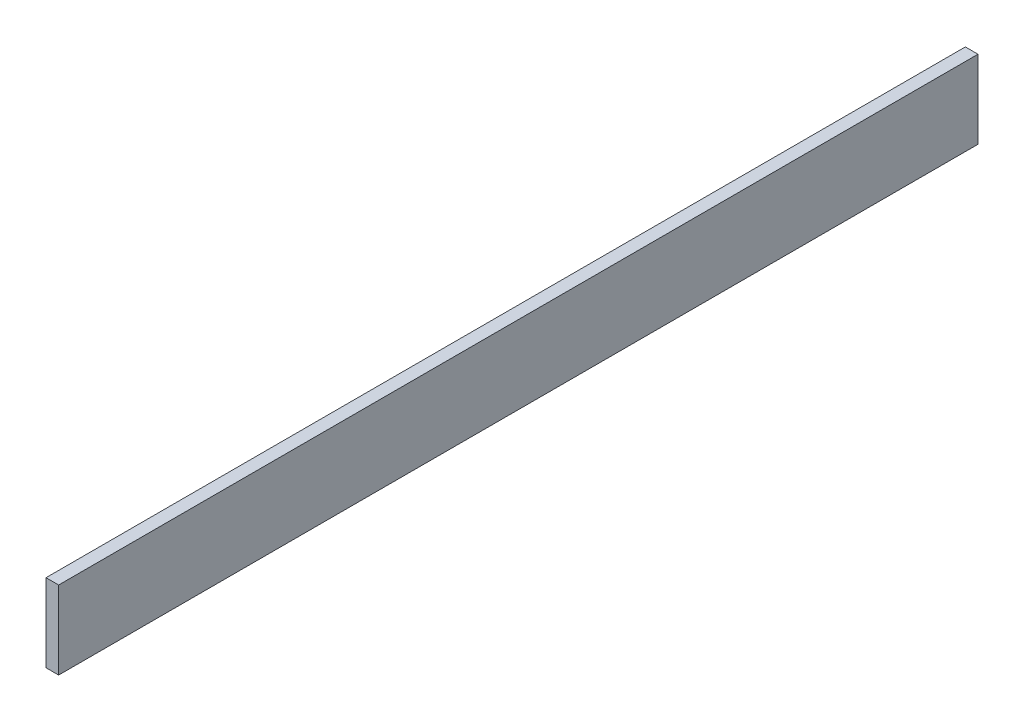
from build123d import *

# Parameters (mm, degrees)
SKETCH1_W           = 2768.6
SKETCH1_H           = 234.95
BOSS_EXTRUDE1_DEPTH = 38.1


with BuildPart() as part:
    # Sketch1 → Boss-Extrude1 (new body)
    with BuildSketch(Plane(origin=(0, 0, 0), x_dir=(0, 0, -1), z_dir=(1, 0, 0))):
        with Locations((1384.3, 117.475)):
            Rectangle(SKETCH1_W, SKETCH1_H)
    extrude(amount=BOSS_EXTRUDE1_DEPTH)


solid = part.part
